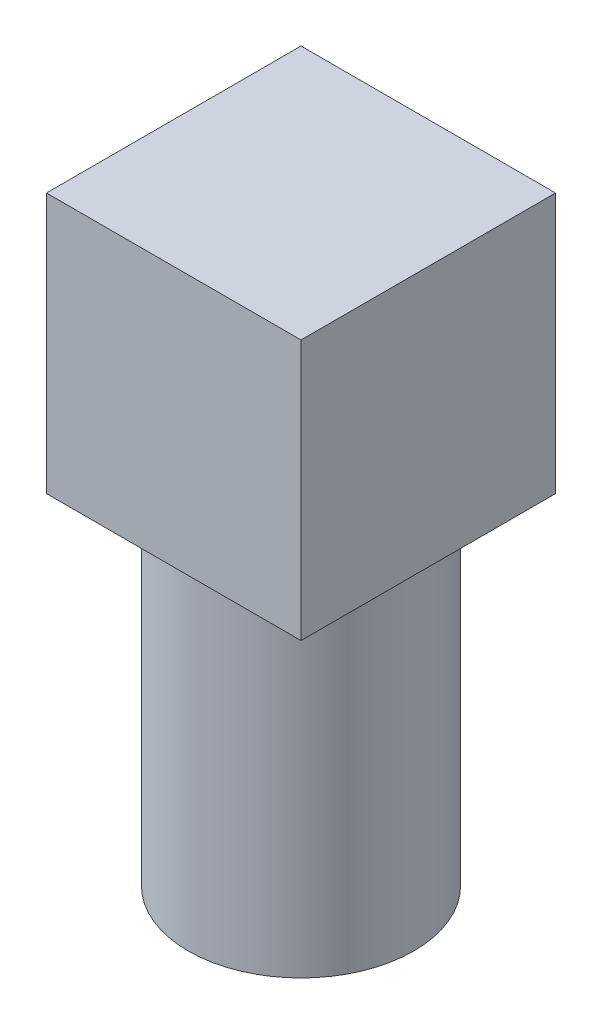
from build123d import *

# Parameters (mm, degrees)
SKETCH2_W           = 44
SKETCH2_H           = 44
BOSS_EXTRUDE1_DEPTH = 45
SKETCH3_R           = 19.5
BOSS_EXTRUDE2_DEPTH = 58.72


with BuildPart() as part:
    # Sketch2 → Boss-Extrude1 (new body)
    with BuildSketch(Plane(origin=(0, 0, 0), x_dir=(1, 0, 0), z_dir=(0, 1, 0))):
        Rectangle(SKETCH2_W, SKETCH2_H)
    extrude(amount=BOSS_EXTRUDE1_DEPTH)

    # Sketch3 → Boss-Extrude2 (add)
    with BuildSketch(Plane.XZ):
        with Locations(Location((0, 0, 0), (0, 0, 270))):  # turned: the seam where the file's is
            Circle(SKETCH3_R)
    extrude(amount=BOSS_EXTRUDE2_DEPTH)


solid = part.part
